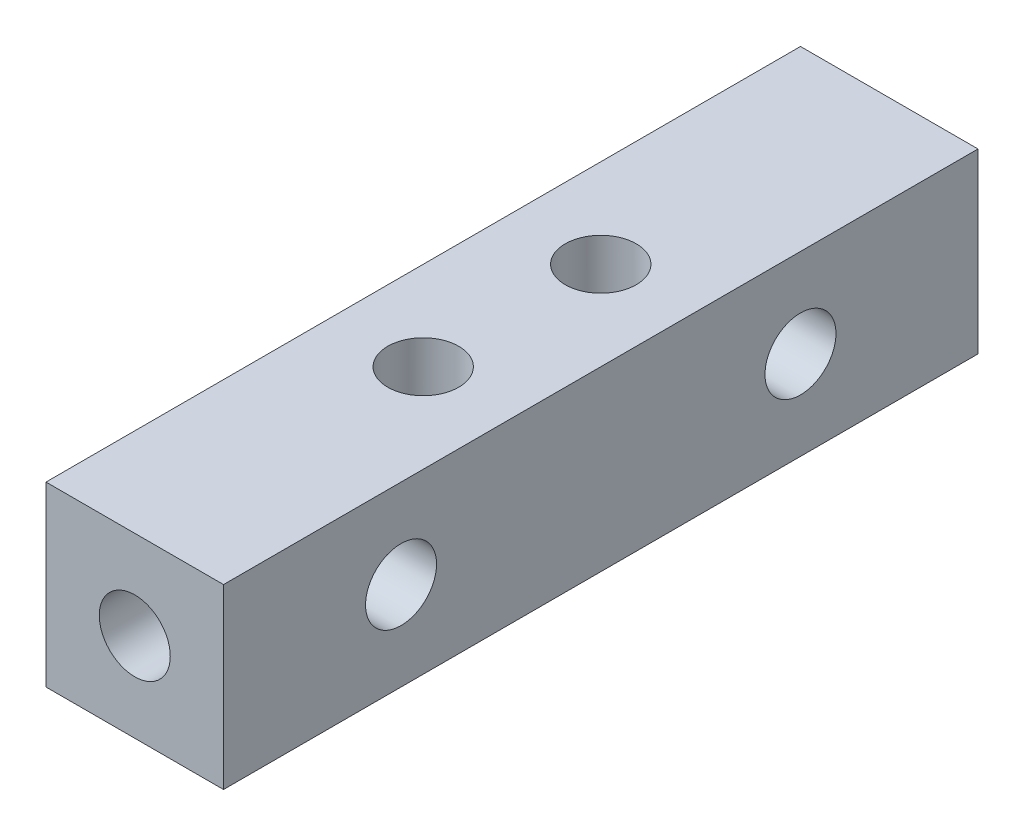
from build123d import *

# Parameters (mm, degrees)
SKETCH_1_W          = 8
SKETCH_1_H          = 8
EXTRUDE_1_DEPTH     = 34
SKETCH_2_R          = 1.6
CUT_EXTRUDE_1_DEPTH = 35
SKETCH_3_R          = 1.6
CUT_EXTRUDE_2_DEPTH = 34
SKETCH_4_R          = 1.6
CUT_EXTRUDE_3_DEPTH = 34


with BuildPart() as part:
    # 草图1 → 凸台-拉伸1 (new body)
    with BuildSketch(Plane.XY):
        with Locations((5.832511347, 6.305290853)):
            Rectangle(SKETCH_1_W, SKETCH_1_H)
    extrude(amount=EXTRUDE_1_DEPTH)

    # 草图2 → 切除-拉伸1 (cut, through all)
    with BuildSketch(Plane.XY.offset(34)):
        with Locations((5.832511347, 6.305290853)):
            Circle(SKETCH_2_R)
    extrude(amount=-CUT_EXTRUDE_1_DEPTH, mode=Mode.SUBTRACT)

    # 草图3 → 切除-拉伸2 (cut)
    with BuildSketch(Plane(origin=(0, 10.305290853, 0), x_dir=(1, 0, 0), z_dir=(0, 1, 0))):
        with Locations((5.832511347, -13)):
            Circle(SKETCH_3_R)
        with Locations((5.832511347, -21)):
            Circle(SKETCH_3_R)
    extrude(amount=-CUT_EXTRUDE_2_DEPTH, mode=Mode.SUBTRACT)

    # 草图4 → 切除-拉伸3 (cut)
    with BuildSketch(Plane(origin=(9.832511347, 0, 0), x_dir=(0, 0, -1), z_dir=(1, 0, 0))):
        with Locations((-26, 6.305290853)):
            Circle(SKETCH_4_R)
        with Locations((-8, 6.305290853)):
            Circle(SKETCH_4_R)
    extrude(amount=-CUT_EXTRUDE_3_DEPTH, mode=Mode.SUBTRACT)


solid = part.part
